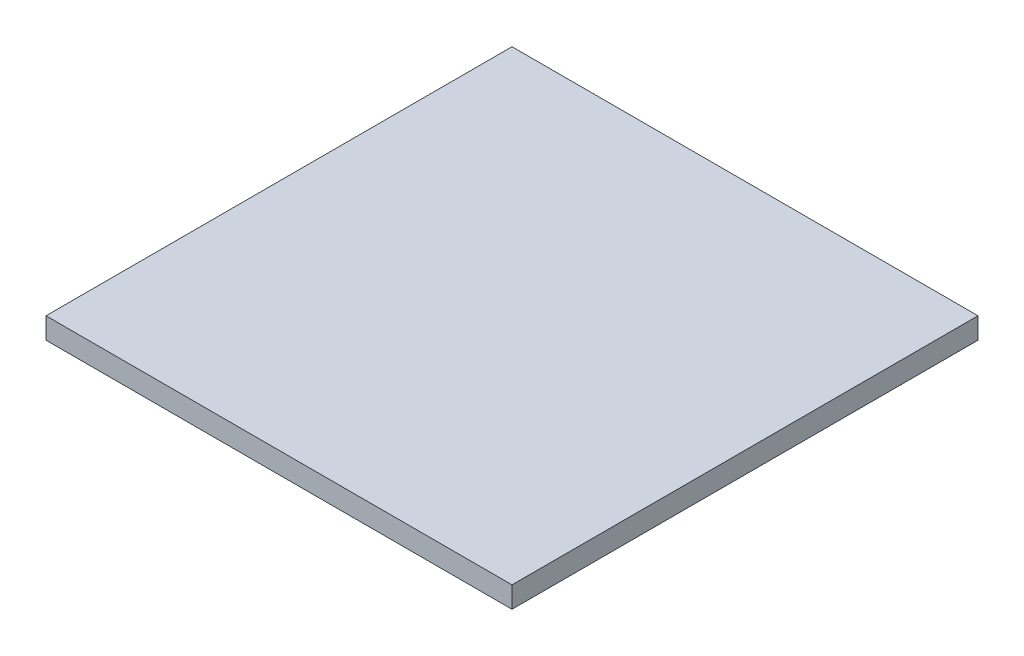
from build123d import *

# Parameters (mm, degrees)
SKETCH1_W           = 279.4
SKETCH1_H           = 279.4
BOSS_EXTRUDE1_DEPTH = 12.7


with BuildPart() as part:
    # Sketch1 → Boss-Extrude1 (new body)
    with BuildSketch(Plane(origin=(0, 0, 0), x_dir=(1, 0, 0), z_dir=(0, 1, 0))):
        with Locations((139.7, 139.7)):
            Rectangle(SKETCH1_W, SKETCH1_H)
    extrude(amount=BOSS_EXTRUDE1_DEPTH)


solid = part.part
